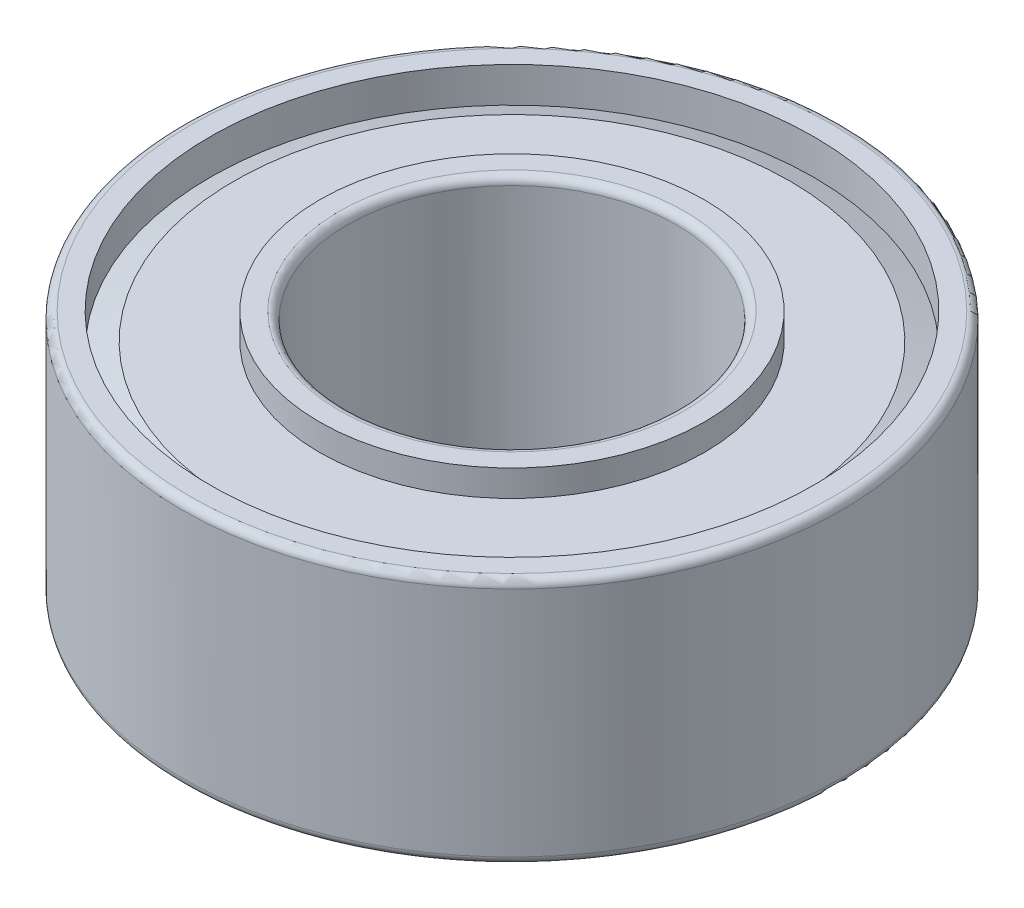
from build123d import *

# Parameters (mm, degrees)
SKETCH1_W = 3.175
SKETCH1_H = 4.7752
SKETCH1_R = 1.2065
FILLET1_R = 0.1524


with BuildPart() as part:
    # Sketch1 → Revolve1 (revolve)
    with BuildSketch(Plane.XY):
        with Locations((4.7625, 2.3876)):
            Rectangle(SKETCH1_W, SKETCH1_H)
        with Locations((4.7625, 2.3876)):
            Circle(SKETCH1_R, mode=Mode.SUBTRACT)
    revolve(axis=Axis((0, 0, 0), (0, 1, 0)))

    # Sketch2 → Cut-Revolve1 (revolve, cut)
    with BuildSketch(Plane.XY):
        Polygon((3.7084, 4.7752), (3.7084, 4.2672), (5.353083782, 4.2672), (5.8166, 4.096323786), (5.8166, 4.7752), align=None)
    cut_revolve1 = revolve(axis=Axis((0, 0, 0), (0, 1, 0)), mode=Mode.SUBTRACT)

    # Mirror1: Cut-Revolve1 across plane
    add(cut_revolve1.mirror(Plane(origin=(0, 2.3876, 0), x_dir=(0, 0, 1), z_dir=(0, -1, 0))), mode=Mode.SUBTRACT)

    # Fillet1
    fillet1_edges = [part.edges().sort_by_distance(p)[0] for p in [
        (-3.175, 4.7752, 0),
        (-6.35, 4.7752, 0),
        (-6.35, 0, 0),
        (-3.175, 0, 0),
    ]]
    fillet(fillet1_edges, radius=FILLET1_R)


solid = part.part
